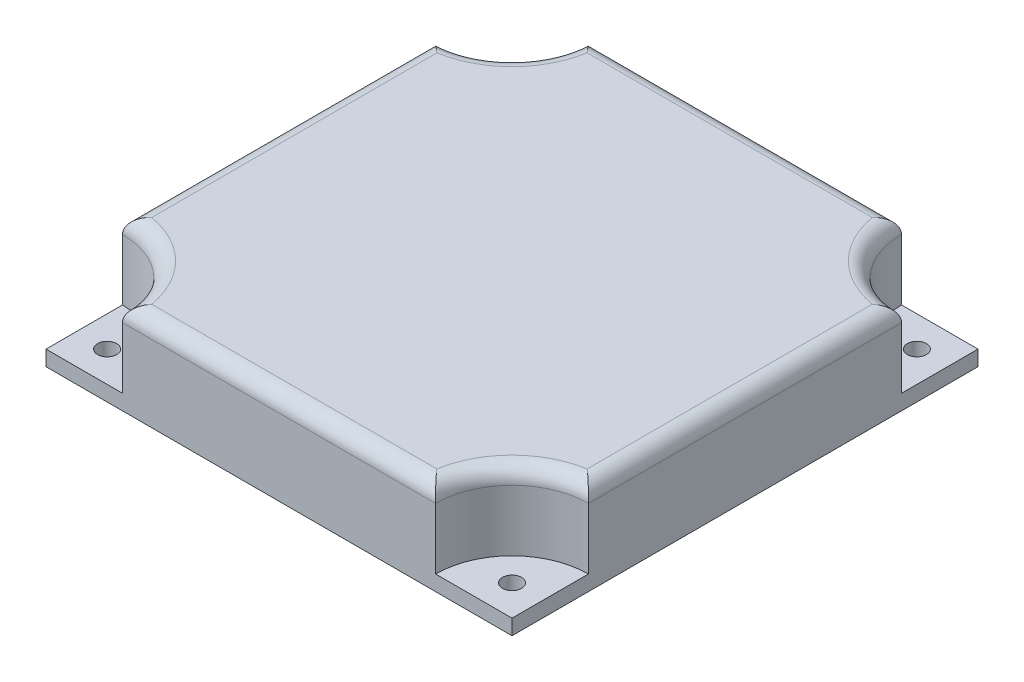
from build123d import *

# Parameters (mm, degrees)
SKETCH2_W           = 61
SKETCH2_H           = 61
BOSS_EXTRUDE1_DEPTH = 12
SKETCH4_R           = 10
CUT_EXTRUDE3_DEPTH  = 10
CUT_EXTRUDE5_DEPTH  = 10
FILLET2_R           = 2
FILLET3_R           = 5


with BuildPart() as part:
    # Sketch2 → Boss-Extrude1 (new body)
    with BuildSketch(Plane(origin=(0, 0, 0), x_dir=(1, 0, 0), z_dir=(0, 1, 0))):
        Rectangle(SKETCH2_W, SKETCH2_H)
    extrude(amount=BOSS_EXTRUDE1_DEPTH)

    # Sketch4 → Cut-Extrude3 (cut)
    with BuildSketch(Plane(origin=(0, 12, 0), x_dir=(1, 0, 0), z_dir=(0, 1, 0))):
        with Locations((30.5, -30.5)):
            Circle(SKETCH4_R)
        with Locations((-30.5, -30.5)):
            Circle(SKETCH4_R)
        with Locations((-30.5, 30.5)):
            Circle(SKETCH4_R)
        with Locations((30.5, 30.5)):
            Circle(SKETCH4_R)
    extrude(amount=-CUT_EXTRUDE3_DEPTH, mode=Mode.SUBTRACT)

    # Sketch8 → Cut-Extrude5 (cut)
    with BuildSketch(Plane.XZ):
        with BuildLine():
            Line((-18.667840434, -28.5), (18.667840434, -28.5))
            ThreePointArc((18.667840434, -28.5), (22.014718626, -22.014718626), (28.5, -18.667840434))
            Line((28.5, -18.667840434), (28.5, 18.667840434))
            ThreePointArc((28.5, 18.667840434), (22.014718626, 22.014718626), (18.667840434, 28.5))
            Line((18.667840434, 28.5), (-18.667840434, 28.5))
            ThreePointArc((-18.667840434, 28.5), (-22.014718626, 22.014718626), (-28.5, 18.667840434))
            Line((-28.5, 18.667840434), (-28.5, -18.667840434))
            ThreePointArc((-28.5, -18.667840434), (-22.014718626, -22.014718626), (-18.667840434, -28.5))
        make_face()
    extrude(amount=-CUT_EXTRUDE5_DEPTH, mode=Mode.SUBTRACT)

    # Fillet2
    fillet2_edges = [part.edges().sort_by_distance(p)[0] for p in [
        (30.5, 12, 0),
        (0, 12, -30.5),
        (-30.5, 12, 0),
        (0, 12, 30.5),
        (23.428932188, 12, -23.428932188),
        (-23.428932188, 12, -23.428932188),
        (-23.428932188, 12, 23.428932188),
        (23.428932188, 12, 23.428932188),
    ]]
    fillet(fillet2_edges, radius=FILLET2_R)

    # Sketch15 → M3x0.5 Tapped Hole1 (revolve, cut)
    with BuildSketch(Plane(origin=(26.5, 2, 26.5), x_dir=(0, 0, 1), z_dir=(1, 0, 0))):
        Polygon((0, 0), (0, 8.251075774), (1.25, 7.5), (1.25, 0), align=None)
    m3x0_5_tapped_hole1 = revolve(axis=Axis((26.5, 8.35, 26.5), (0, -1, 0)), mode=Mode.SUBTRACT)

    # Mirror1: M3x0.5 Tapped Hole1 across plane
    add(m3x0_5_tapped_hole1.mirror(Plane.XY), mode=Mode.SUBTRACT)

    # Mirror2: M3x0.5 Tapped Hole1 across plane
    add(m3x0_5_tapped_hole1.mirror(Plane(origin=(0, 0, 0), x_dir=(0, 0, 1), z_dir=(1, 0, 0))), mode=Mode.SUBTRACT)

    # Mirror2 copy 1 sketch → Mirror2 copy 1 (revolve, cut)
    with BuildSketch(Plane(origin=(-26.5, 2, -26.5), x_dir=(0, 0, -1), z_dir=(-1, 0, 0))):
        Polygon((0, 0), (0, 8.251075774), (1.25, 7.5), (1.25, 0), align=None)
    revolve(axis=Axis((-26.5, 8.35, -26.5), (0, -1, 0)), mode=Mode.SUBTRACT)

    # Fillet3
    fillet3_edges = [part.edges().sort_by_distance(p)[0] for p in [
        (28.5, 5, -18.667840434),
        (18.667840434, 5, -28.5),
        (-18.667840434, 5, -28.5),
        (-28.5, 5, -18.667840434),
        (-28.5, 5, 18.667840434),
        (-18.667840434, 5, 28.5),
        (18.667840434, 5, 28.5),
        (28.5, 5, 18.667840434),
    ]]
    fillet(fillet3_edges, radius=FILLET3_R)


solid = part.part
